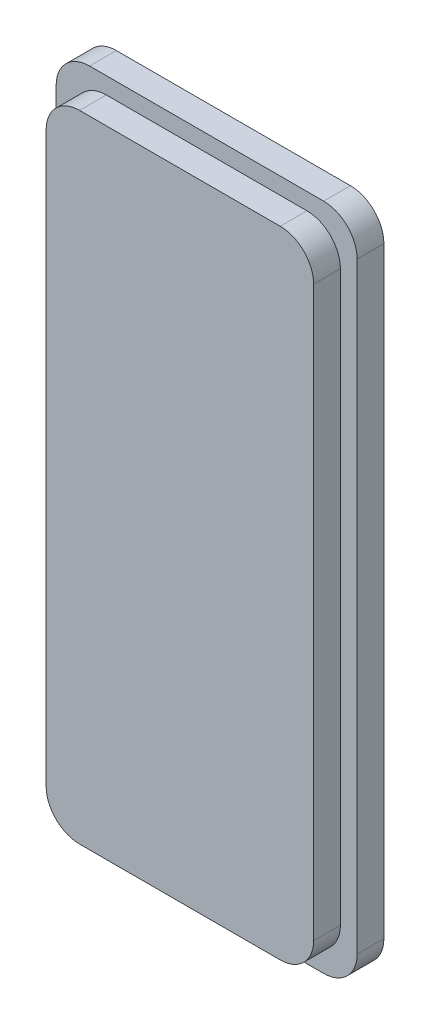
from build123d import *

# Parameters (mm, degrees)
SKETCH_1_W      = 45
SKETCH_1_H      = 100
EXTRUDE_1_DEPTH = 4
SKETCH_2_W      = 40
SKETCH_2_H      = 95
EXTRUDE_2_DEPTH = 4
FILLET_1_R      = 5


with BuildPart() as part:
    # 草圖1 → 填料-伸長1 (new body)
    with BuildSketch(Plane.XY):
        Rectangle(SKETCH_1_W, SKETCH_1_H)
    extrude(amount=EXTRUDE_1_DEPTH)

    # 草圖2 → 填料-伸長2 (add)
    with BuildSketch(Plane.XY.offset(4)):
        Rectangle(SKETCH_2_W, SKETCH_2_H)
    extrude(amount=EXTRUDE_2_DEPTH)

    # 圓角1
    fillet_1_edges = [part.edges().sort_by_distance(p)[0] for p in [
        (20, -47.5, 6),
        (20, 47.5, 6),
        (-20, 47.5, 6),
        (-20, -47.5, 6),
        (22.5, -50, 2),
        (-22.5, -50, 2),
        (-22.5, 50, 2),
        (22.5, 50, 2),
    ]]
    fillet(fillet_1_edges, radius=FILLET_1_R)


solid = part.part
